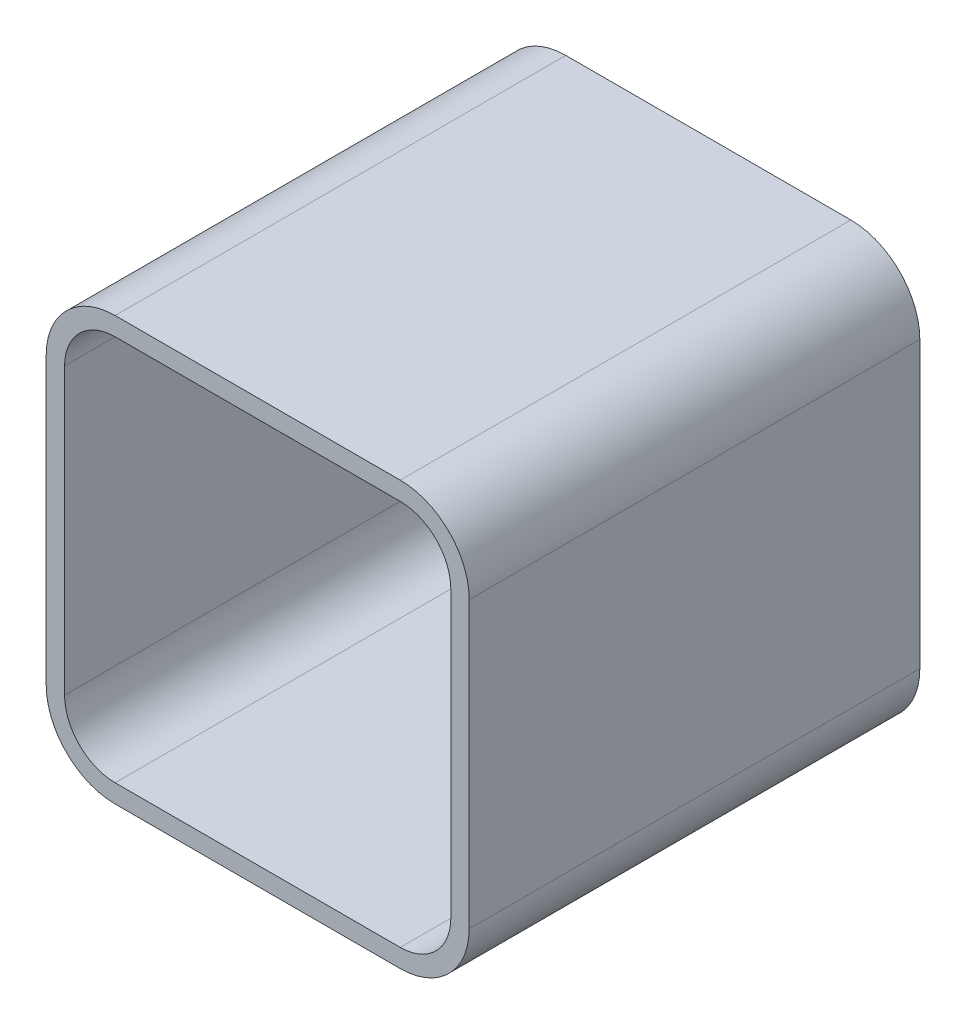
from build123d import *

# Parameters (mm, degrees)
SKETCH1_W           = 42
SKETCH1_H           = 42
BOSS_EXTRUDE1_DEPTH = 2
FILLET1_R           = 5.5
BOSS_EXTRUDE2_DEPTH = 49


with BuildPart() as part:
    # Sketch1 → Boss-Extrude1 (new body)
    with BuildSketch(Plane.XY):
        Rectangle(SKETCH1_W, SKETCH1_H)
    extrude(amount=BOSS_EXTRUDE1_DEPTH)

    # Fillet1
    fillet1_edges = [part.edges().sort_by_distance(p)[0] for p in [
        (-21, 21, 1),
        (21, 21, 1),
        (21, -21, 1),
        (-21, -21, 1),
    ]]
    fillet(fillet1_edges, radius=FILLET1_R)

    # Sketch2 → Boss-Extrude2 (add)
    with BuildSketch(Plane.XY):
        with BuildLine():
            Line((-23, 15.5), (-23, -15.5))
            ThreePointArc((-23, -15.5), (-20.803300859, -20.803300859), (-15.5, -23))
            Line((-15.5, -23), (15.5, -23))
            ThreePointArc((15.5, -23), (20.803300859, -20.803300859), (23, -15.5))
            Line((23, -15.5), (23, 15.5))
            ThreePointArc((23, 15.5), (20.803300859, 20.803300859), (15.5, 23))
            Line((15.5, 23), (-15.5, 23))
            ThreePointArc((-15.5, 23), (-20.803300859, 20.803300859), (-23, 15.5))
        make_face()
        with BuildLine():
            Line((-21, 15.5), (-21, -15.5))
            ThreePointArc((-21, -15.5), (-19.389087297, -19.389087297), (-15.5, -21))
            Line((-15.5, -21), (15.5, -21))
            ThreePointArc((15.5, -21), (19.389087297, -19.389087297), (21, -15.5))
            Line((21, -15.5), (21, 15.5))
            ThreePointArc((21, 15.5), (19.389087297, 19.389087297), (15.5, 21))
            Line((15.5, 21), (-15.5, 21))
            ThreePointArc((-15.5, 21), (-19.389087297, 19.389087297), (-21, 15.5))
        make_face(mode=Mode.SUBTRACT)
    extrude(amount=BOSS_EXTRUDE2_DEPTH)


solid = part.part
